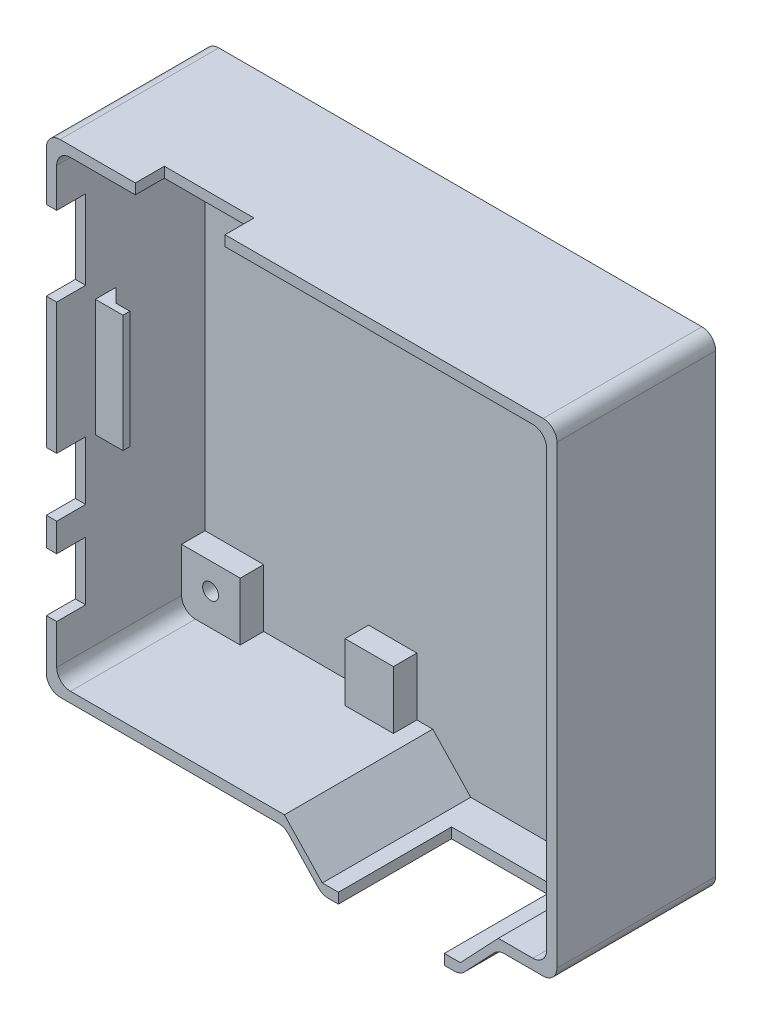
from build123d import *

# Parameters (mm, degrees)
BOSS_EXTRU_1_DEPTH      = 23
ENL_V_MAT_EXTRU_1_DEPTH = 21.5
ESQUISSE3_W             = 8.5
ESQUISSE3_H             = 8.4
BOSS_EXTRU_3_DEPTH      = 3.4
BOSS_EXTRU_5_REACH      = 9.309
ESQUISSE4_W             = 1.5
ESQUISSE4_H             = 3.406602833
ESQUISSE23_R            = 1.15
ENL_V_MAT_EXTRU_2_DEPTH = 4
ESQUISSE24_W            = 7
ESQUISSE24_H            = 8.4
BOSS_EXTRU_6_DEPTH      = 3.4
ENL_V_MAT_EXTRU_4_REACH = 77.809
ESQUISSE26_W            = 15.35
ESQUISSE26_H            = 16.4
ESQUISSE27_W            = 1
ESQUISSE27_H            = 17
BOSS_EXTRU_7_DEPTH      = 4
CHANFREIN1_SIZE         = 2
ENL_V_MAT_EXTRU_5_REACH = 76
ESQUISSE28_W            = 4.2
ESQUISSE28_H            = 11.5
ENL_V_MAT_EXTRU_6_REACH = 76
ESQUISSE29_W            = 4.2
ESQUISSE29_H            = 8.5
ESQUISSE30_W            = 13
ESQUISSE30_H            = 4.2
ENL_V_MAT_EXTRU_8_DEPTH = 4
CONG_1_R                = 2


with BuildPart() as part:
    # Esquisse1 → Boss.-Extru.1 (new body)
    with BuildSketch(Plane.XY):
        Polygon((-2.5, -35), (3, -40.809475019), (23, -40.809475019), (28.5, -35), (37, -35), (37, 35), (-37, 35), (-37, -35), align=None)
    extrude(amount=BOSS_EXTRU_1_DEPTH)

    # Esquisse2 → Enlèv. mat.-Extru.1 (cut)
    with BuildSketch(Plane.XY.offset(23)):
        Polygon((-2.5, -33.5), (3, -39.309475019), (23, -39.309475019), (28.5, -33.5), (35.5, -33.5), (35.5, 33.5), (-35.5, 33.5), (-35.5, -33.5), align=None)
    extrude(amount=-ENL_V_MAT_EXTRU_1_DEPTH, mode=Mode.SUBTRACT)

    # Esquisse3 → Boss.-Extru.3 (add)
    with BuildSketch(Plane.XY.offset(1.5)):
        with Locations((31.25, 29.3)):
            Rectangle(ESQUISSE3_W, ESQUISSE3_H)
        with Locations((-31.25, 29.3)):
            Rectangle(ESQUISSE3_W, ESQUISSE3_H)
        with Locations((31.25, -29.3)):
            Rectangle(ESQUISSE3_W, ESQUISSE3_H)
        with Locations((-31.25, -29.3)):
            Rectangle(ESQUISSE3_W, ESQUISSE3_H)
    extrude(amount=BOSS_EXTRU_3_DEPTH)

    # Esquisse4 → Boss.-Extru.5 (add, up to next)
    with BuildSketch(Plane.XZ.offset(33.5), mode=Mode.PRIVATE) as boss_extru_5_sk1:
        with Locations((27.75, 3.196698584)):
            Rectangle(ESQUISSE4_W, ESQUISSE4_H)
    boss_extru_5_tool1 = extrude(boss_extru_5_sk1.sketch, amount=BOSS_EXTRU_5_REACH, mode=Mode.PRIVATE) - part.part
    add(boss_extru_5_tool1.solids().sort_by_distance((27.75, -33.5, 3.196699))[0])

    # Esquisse23 → Enlèv. mat.-Extru.2 (cut)
    with BuildSketch(Plane.XY.offset(4.9)):
        with Locations((31.3, 29.3)):
            Circle(ESQUISSE23_R)
        with Locations((-31.3, 29.3)):
            Circle(ESQUISSE23_R)
        with Locations((31.3, -28.9)):
            Circle(ESQUISSE23_R)
        with Locations((-31.3, -28.9)):
            Circle(ESQUISSE23_R)
    extrude(amount=-ENL_V_MAT_EXTRU_2_DEPTH, mode=Mode.SUBTRACT)

    # Esquisse24 → Boss.-Extru.6 (add)
    with BuildSketch(Plane.XY.offset(1.5)):
        with Locations((-8.3, 29.3)):
            Rectangle(ESQUISSE24_W, ESQUISSE24_H)
        with Locations((-8.3, -29.3)):
            Rectangle(ESQUISSE24_W, ESQUISSE24_H)
    extrude(amount=BOSS_EXTRU_6_DEPTH)

    # Esquisse26 → Enlèv. mat.-Extru.4 (cut, up to next)
    with BuildSketch(Plane.XZ.offset(40.809475019), mode=Mode.PRIVATE) as enl_v_mat_extru_4_sk1:
        with Locations((13, 14.8)):
            Rectangle(ESQUISSE26_W, ESQUISSE26_H)
    enl_v_mat_extru_4_tool1 = extrude(enl_v_mat_extru_4_sk1.sketch, amount=-ENL_V_MAT_EXTRU_4_REACH, mode=Mode.PRIVATE) & part.part
    add(enl_v_mat_extru_4_tool1.solids().sort_by_distance((13, -40.809475, 14.8))[0], mode=Mode.SUBTRACT)

    # Esquisse27 → Boss.-Extru.7 (add)
    with BuildSketch(Plane(origin=(-35.5, 0, 0), x_dir=(0, 0, -1), z_dir=(1, 0, 0))):
        with Locations((-16.9, 3.4)):
            Rectangle(ESQUISSE27_W, ESQUISSE27_H)
    extrude(amount=BOSS_EXTRU_7_DEPTH)

    # Chanfrein1
    chanfrein1_edges = [part.edges().sort_by_distance(p)[0] for p in [
        (-35.5, 3.4, 16.4),
    ]]
    chamfer(chanfrein1_edges, length=CHANFREIN1_SIZE)

    # Esquisse28 → Enlèv. mat.-Extru.5 (cut, up to next)
    with BuildSketch(Plane.ZY.offset(37), mode=Mode.PRIVATE) as enl_v_mat_extru_5_sk1:
        with Locations((20.9, 20.1)):
            Rectangle(ESQUISSE28_W, ESQUISSE28_H)
    enl_v_mat_extru_5_tool1 = extrude(enl_v_mat_extru_5_sk1.sketch, amount=-ENL_V_MAT_EXTRU_5_REACH, mode=Mode.PRIVATE) & part.part
    add(enl_v_mat_extru_5_tool1.solids().sort_by_distance((-37, 20.1, 20.9))[0], mode=Mode.SUBTRACT)

    # Esquisse29 → Enlèv. mat.-Extru.6 (cut, up to next)
    with BuildSketch(Plane.ZY.offset(37), mode=Mode.PRIVATE) as enl_v_mat_extru_6_sk1:
        with Locations((20.9, -8.9)):
            Rectangle(ESQUISSE29_W, ESQUISSE29_H)
    enl_v_mat_extru_6_tool1 = extrude(enl_v_mat_extru_6_sk1.sketch, amount=-ENL_V_MAT_EXTRU_6_REACH, mode=Mode.PRIVATE) & part.part
    add(enl_v_mat_extru_6_tool1.solids().sort_by_distance((-37, -8.9, 20.9))[0], mode=Mode.SUBTRACT)
    # Esquisse29 → Enlèv. mat.-Extru.6 (cut, up to next)
    with BuildSketch(Plane.ZY.offset(37), mode=Mode.PRIVATE) as enl_v_mat_extru_6_sk2:
        with Locations((20.9, -21.5)):
            Rectangle(ESQUISSE29_W, ESQUISSE29_H)
    enl_v_mat_extru_6_tool2 = extrude(enl_v_mat_extru_6_sk2.sketch, amount=-ENL_V_MAT_EXTRU_6_REACH, mode=Mode.PRIVATE) & part.part
    add(enl_v_mat_extru_6_tool2.solids().sort_by_distance((-37, -21.5, 20.9))[0], mode=Mode.SUBTRACT)

    # Esquisse30 → Enlèv. mat.-Extru.8 (cut)
    with BuildSketch(Plane(origin=(0, 35, 0), x_dir=(1, 0, 0), z_dir=(0, 1, 0))):
        with Locations((-17.6, -20.9)):
            Rectangle(ESQUISSE30_W, ESQUISSE30_H)
    extrude(amount=-ENL_V_MAT_EXTRU_8_DEPTH, mode=Mode.SUBTRACT)

    # Congé1
    cong_1_edges = [part.edges().sort_by_distance(p)[0] for p in [
        (28.5, -35, 11.5),
        (23, -40.809475019, 11.5),
        (3, -40.809475019, 11.5),
        (-2.5, -35, 11.5),
        (-37, -35, 11.5),
        (-37, 35, 11.5),
        (37, 35, 11.5),
        (37, -35, 11.5),
        (35.5, 33.5, 13.95),
        (-35.5, 33.5, 13.95),
        (35.5, -33.5, 13.95),
        (-35.5, -33.5, 13.95),
    ]]
    fillet(cong_1_edges, radius=CONG_1_R)


solid = part.part
